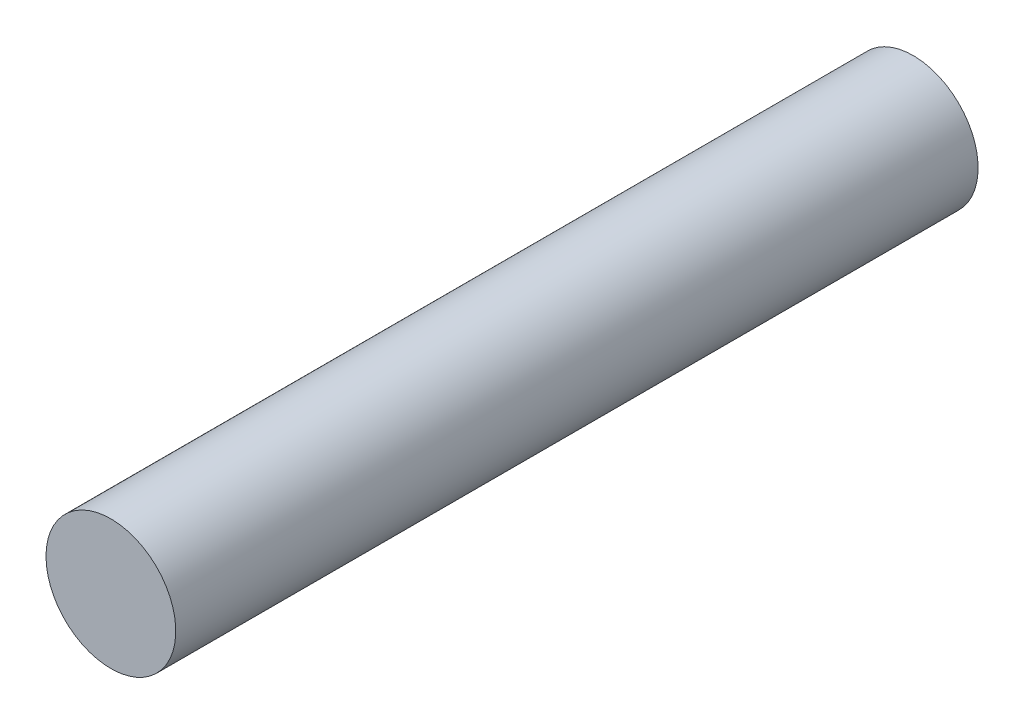
from build123d import *

# Parameters (mm, degrees)
EXTRUDE_2_DEPTH = 100
SKETCH_2_R      = 10.511735391
EXTRUDE_3_DEPTH = 130


with BuildPart() as part:
    # 草图1 → 凸台-拉伸2 (new body)
    with BuildSketch(Plane.XY):
        with BuildLine():
            Line((0, 0), (21, 0))
            ThreePointArc((21, 0), (10.5, 10.5), (0, 0))
        make_face()
    extrude(amount=EXTRUDE_2_DEPTH)

    # 草图2 → 凸台-拉伸3 (add)
    with BuildSketch(Plane(origin=(0, 0, 0), x_dir=(-1, 0, 0), z_dir=(0, 0, -1))):
        with Locations((-10.5, 0)):
            Circle(SKETCH_2_R)
    extrude(amount=-EXTRUDE_3_DEPTH)


solid = part.part
